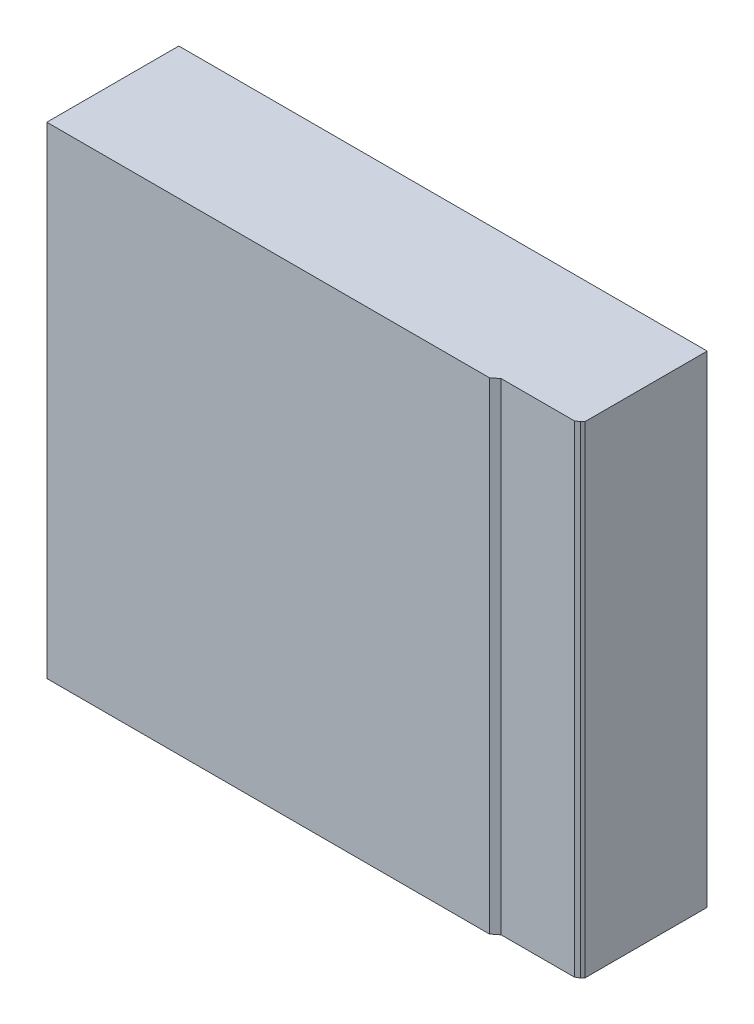
from build123d import *

# Parameters (mm, degrees)
EXTRUDE_1_DEPTH = 730


with BuildPart() as part:
    # Эскиз1 → Бобышка-Вытянуть1 (new body)
    with BuildSketch(Plane(origin=(0, 0, 0), x_dir=(1, 0, 0), z_dir=(0, 1, 0))):
        Polygon((0, 0), (670.632596603, 0), (680.632596603, 7.810241479), (791.427044457, 7.810241479), (797.288486629, 11.299644972), (800.632596603, 15), (800.632596603, 200), (0, 200), align=None)
    extrude(amount=EXTRUDE_1_DEPTH)


solid = part.part
